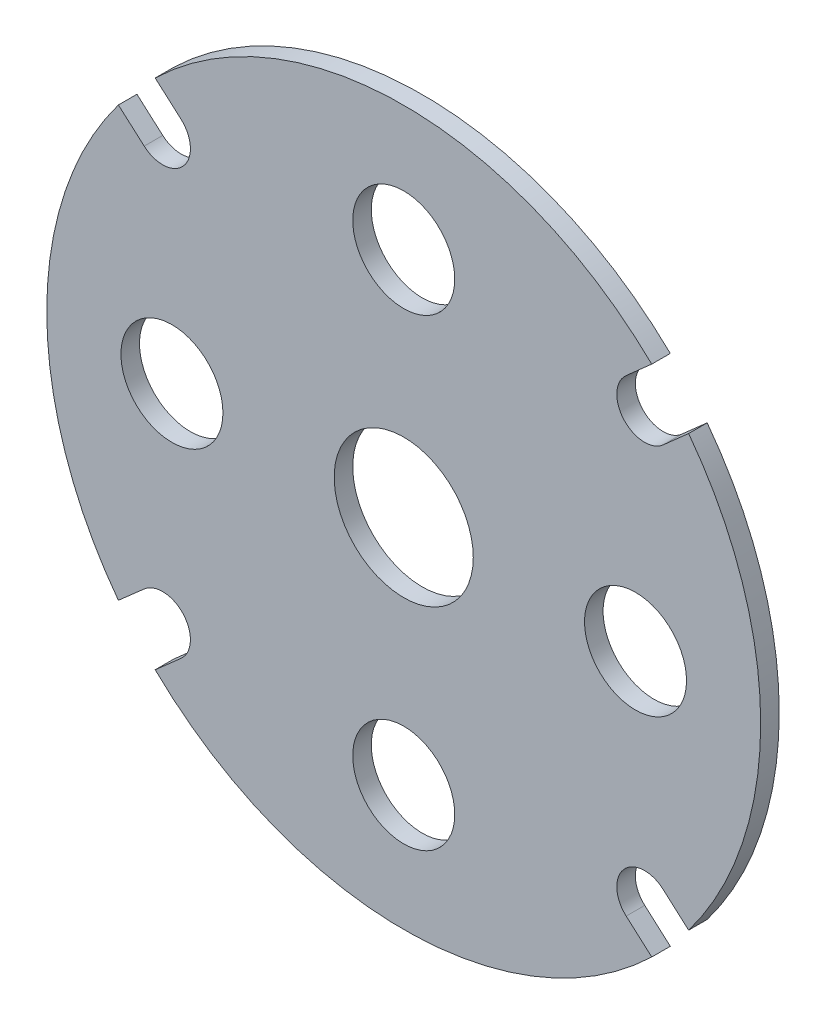
from build123d import *

# Parameters (mm, degrees)
MODEL_R             = 7.5
MODEL_R_2           = 5.5
BOSS_EXTRUDE1_DEPTH = 2


with BuildPart() as part:
    # Model → Boss-Extrude1 (new body)
    with BuildSketch(Plane.XY):
        with BuildLine():
            Line((30.727892071, -23.195832576), (27.969309055, -20.753740651))
            ThreePointArc((27.969309055, -20.753740651), (23.734502764, -21.011453059), (23.992215172, -25.246259349))
            Line((23.992215172, -25.246259349), (26.750798188, -27.688351274))
            ThreePointArc((26.750798188, -27.688351274), (-0.037885337, -38.49998136), (-26.805238954, -27.635650248))
            Line((-26.805238954, -27.635650248), (-24.022447477, -25.18187917))
            ThreePointArc((-24.022447477, -25.18187917), (-23.756401179, -20.947588277), (-27.990692072, -20.68154198))
            Line((-27.990692072, -20.68154198), (-30.773483549, -23.135313057))
            ThreePointArc((-30.773483549, -23.135313057), (-38.5, 0), (-30.773483549, 23.135313057))
            Line((-30.773483549, 23.135313057), (-27.990692072, 20.68154198))
            ThreePointArc((-27.990692072, 20.68154198), (-23.756401179, 20.947588277), (-24.022447477, 25.18187917))
            Line((-24.022447477, 25.18187917), (-26.805238954, 27.635650248))
            ThreePointArc((-26.805238954, 27.635650248), (-0.037885337, 38.49998136), (26.750798188, 27.688351274))
            Line((26.750798188, 27.688351274), (23.992215172, 25.246259349))
            ThreePointArc((23.992215172, 25.246259349), (23.734502764, 21.011453059), (27.969309055, 20.753740651))
            Line((27.969309055, 20.753740651), (30.727892071, 23.195832576))
            ThreePointArc((30.727892071, 23.195832576), (38.5, 0), (30.727892071, -23.195832576))
        make_face()
        Circle(MODEL_R, mode=Mode.SUBTRACT)
        with Locations((-25, 0)):
            Circle(MODEL_R_2, mode=Mode.SUBTRACT)
        with Locations((0, 25)):
            Circle(MODEL_R_2, mode=Mode.SUBTRACT)
        with Locations((0, -25)):
            Circle(MODEL_R_2, mode=Mode.SUBTRACT)
        with Locations((25, 0)):
            Circle(MODEL_R_2, mode=Mode.SUBTRACT)
    extrude(amount=BOSS_EXTRUDE1_DEPTH)


solid = part.part
